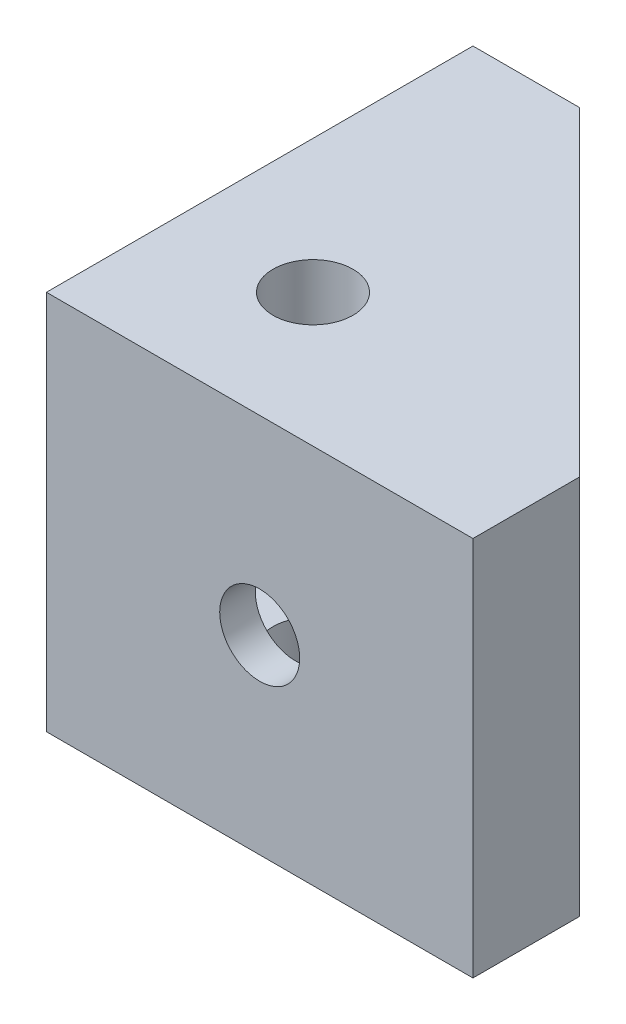
from build123d import *

# Parameters (mm, degrees)
MAIN_BODY_DEPTH              = 34
SKETCH3_R                    = 3.571875
F_9_32_RIGHT_RAIL_DEPTH      = 1
F_9_32_RIGHT_RAIL_DEPTH_BACK = 39.1
SKETCH4_R                    = 3.571875
F_9_32_LEFT_RAIL_DEPTH       = 34
INNER_HOLLOW_DEPTH           = 21.3
SKETCH6_R                    = 3.571875
F_9_32_TOP_HOLE_DEPTH        = 1
F_9_32_TOP_HOLE_DEPTH_BACK   = 35


with BuildPart() as part:
    # Sketch1 → Main Body (new body)
    with BuildSketch(Plane(origin=(0, 0, 0), x_dir=(1, 0, 0), z_dir=(0, 1, 0))):
        Polygon((0, 0), (38.1, 0), (38.1, 9.525), (9.525, 38.1), (0, 38.1), align=None)
    extrude(amount=MAIN_BODY_DEPTH)

    # Sketch3 → 9/32 Right Rail (cut, two sides)
    with BuildSketch(Plane.XY) as f_9_32_right_rail_sk:
        with Locations((19.05, 17)):
            Circle(SKETCH3_R)
    extrude(amount=F_9_32_RIGHT_RAIL_DEPTH, mode=Mode.SUBTRACT)
    extrude(f_9_32_right_rail_sk.sketch, amount=-F_9_32_RIGHT_RAIL_DEPTH_BACK, mode=Mode.SUBTRACT)

    # Sketch4 → 9/32 Left Rail (cut)
    with BuildSketch(Plane.ZY):
        with Locations((-19.05, 17)):
            Circle(SKETCH4_R)
    extrude(amount=-F_9_32_LEFT_RAIL_DEPTH, mode=Mode.SUBTRACT)

    # Sketch5 → Inner Hollow (cut)
    with BuildSketch(Plane(origin=(0, 27.65, 0), x_dir=(1, 0, 0), z_dir=(0, 1, 0))):
        Polygon((3.175, 28.382403955), (11.208798023, 36.416201977), (36.416201977, 11.208798023), (28.382403955, 3.175), (3.175, 3.175), align=None)
    extrude(amount=-INNER_HOLLOW_DEPTH, mode=Mode.SUBTRACT)

    # Sketch6 → 9/32 Top Hole (cut, two sides)
    with BuildSketch(Plane(origin=(0, 34, 0), x_dir=(1, 0, 0), z_dir=(0, 1, 0))) as f_9_32_top_hole_sk:
        with Locations((11.90625, 11.90625)):
            Circle(SKETCH6_R)
    extrude(amount=F_9_32_TOP_HOLE_DEPTH, mode=Mode.SUBTRACT)
    extrude(f_9_32_top_hole_sk.sketch, amount=-F_9_32_TOP_HOLE_DEPTH_BACK, mode=Mode.SUBTRACT)


solid = part.part
